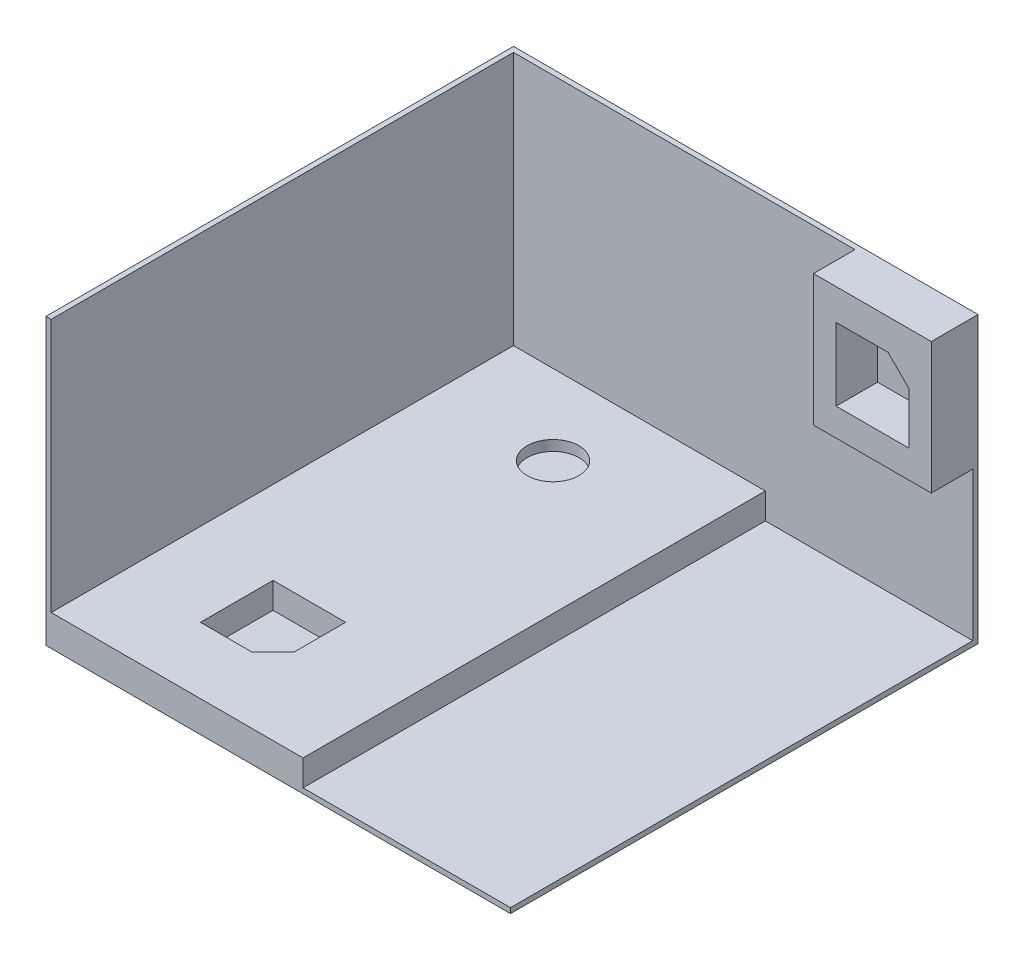
from build123d import *

# Parameters (mm, degrees)
SKETCH1_W           = 5080.67056
SKETCH1_H           = 11322.27229855
SKETCH1_W_2         = 6167.92772
SKETCH1_R           = 635
SKETCH1_H_2         = 127.83180145
BOSS_EXTRUDE1_DEPTH = 127
SKETCH1_3_W         = 6167.92772
SKETCH1_3_H         = 11322.27229855
SKETCH1_3_R         = 635
SKETCH1_3_W_2       = 5080.67056
SKETCH1_3_H_2       = 127.83180145
BOSS_EXTRUDE2_DEPTH = 762
SKETCH1_4_W         = 5080.67056
SKETCH1_4_H         = 127.83180145
BOSS_EXTRUDE3_DEPTH = 6981.20524
SKETCH1_6_R         = 635
BOSS_EXTRUDE5_DEPTH = 508
SKETCH2_W           = 2883.65946
SKETCH2_H           = 3214.67988
BOSS_EXTRUDE6_DEPTH = 1016


with BuildPart() as part:
    # Sketch1 → Boss-Extrude1 (new body)
    with BuildSketch(Plane(origin=(0, 0, 0), x_dir=(1, 0, 0), z_dir=(0, 1, 0))):
        with Locations((3147.46386, -63.915900725)):
            Rectangle(SKETCH1_W, SKETCH1_H)
        with Locations((-2476.83528, -63.915900725)):
            Rectangle(SKETCH1_W_2, SKETCH1_H)
        Polygon((-1747.77654, -2327.20261), (-1747.77654, -3597.20261), (-2255.77654, -4105.20261), (-3525.77654, -4105.20261), (-3525.77654, -2327.20261), align=None, mode=Mode.SUBTRACT)
        with Locations((-2636.77654, 3641.79739)):
            Circle(SKETCH1_R, mode=Mode.SUBTRACT)
        Polygon((607.12858, 5597.22024855), (607.12858, 5725.05205), (-5687.79914, 5725.05205), (-5687.79914, -5725.05205), (-5560.79914, -5725.05205), (-5560.79914, 5597.22024855), align=None)
        with Locations((3147.46386, 5661.136149275)):
            Rectangle(SKETCH1_W, SKETCH1_H_2)
        Polygon((-1747.77654, -2327.20261), (-1747.77654, -3597.20261), (-2255.77654, -4105.20261), (-3525.77654, -4105.20261), (-3525.77654, -2327.20261), align=None)
        with Locations((-2636.77654, 3641.79739)):
            Circle(SKETCH1_R)
    extrude(amount=BOSS_EXTRUDE1_DEPTH)

    # Sketch1_3 → Boss-Extrude2 (add)
    with BuildSketch(Plane(origin=(0, 0, 0), x_dir=(1, 0, 0), z_dir=(0, 1, 0))):
        with Locations((-2476.83528, -63.915900725)):
            Rectangle(SKETCH1_3_W, SKETCH1_3_H)
        Polygon((-1747.77654, -2327.20261), (-1747.77654, -3597.20261), (-2255.77654, -4105.20261), (-3525.77654, -4105.20261), (-3525.77654, -2327.20261), align=None, mode=Mode.SUBTRACT)
        with Locations((-2636.77654, 3641.79739)):
            Circle(SKETCH1_3_R, mode=Mode.SUBTRACT)
        Polygon((607.12858, 5597.22024855), (607.12858, 5725.05205), (-5687.79914, 5725.05205), (-5687.79914, -5725.05205), (-5560.79914, -5725.05205), (-5560.79914, 5597.22024855), align=None)
        with Locations((3147.46386, 5661.136149275)):
            Rectangle(SKETCH1_3_W_2, SKETCH1_3_H_2)
    extrude(amount=BOSS_EXTRUDE2_DEPTH)

    # Sketch1_4 → Boss-Extrude3 (add)
    with BuildSketch(Plane(origin=(0, 0, 0), x_dir=(1, 0, 0), z_dir=(0, 1, 0))):
        with Locations((3147.46386, 5661.136149275)):
            Rectangle(SKETCH1_4_W, SKETCH1_4_H)
        Polygon((607.12858, 5597.22024855), (607.12858, 5725.05205), (-5687.79914, 5725.05205), (-5687.79914, -5725.05205), (-5560.79914, -5725.05205), (-5560.79914, 5597.22024855), align=None)
    extrude(amount=BOSS_EXTRUDE3_DEPTH)

    # Sketch1_6 → Boss-Extrude5 (add)
    with BuildSketch(Plane(origin=(0, 0, 0), x_dir=(1, 0, 0), z_dir=(0, 1, 0))):
        with Locations((-2636.77654, 3641.79739)):
            Circle(SKETCH1_6_R)
    extrude(amount=BOSS_EXTRUDE5_DEPTH)

    # Sketch2 → Boss-Extrude6 (add)
    with BuildSketch(Plane.XY.offset(-5597.22024855)):
        with Locations((4245.96941, 5373.8653)):
            Rectangle(SKETCH2_W, SKETCH2_H)
        Polygon((4627.62346, 6223), (5135.62346, 5715), (5135.62346, 4445), (3357.62346, 4445), (3357.62346, 6223), align=None, mode=Mode.SUBTRACT)
    extrude(amount=BOSS_EXTRUDE6_DEPTH)


solid = part.part
